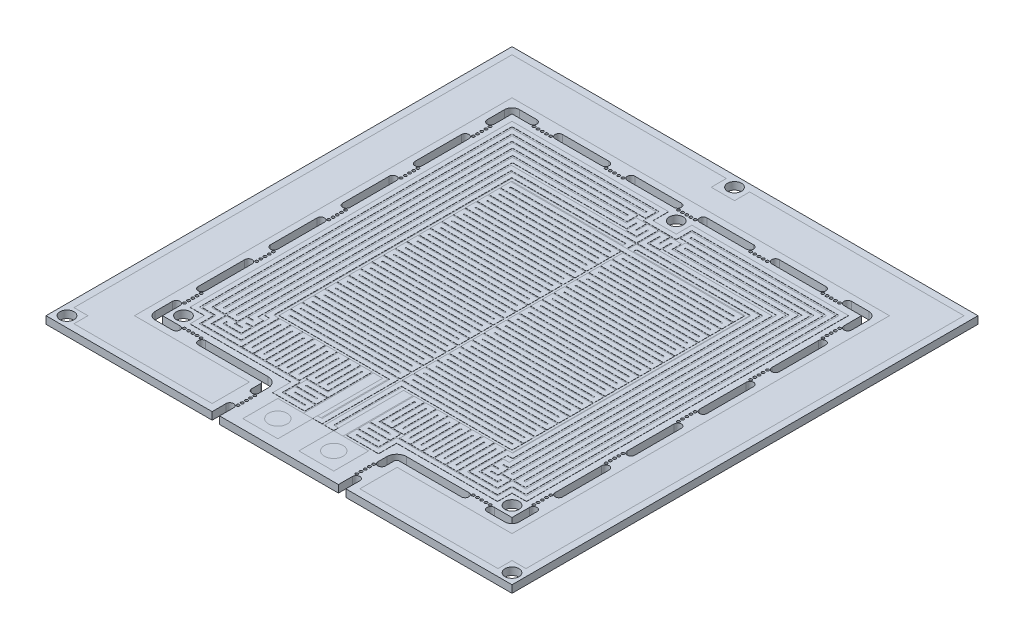
from build123d import *

# Parameters (mm, degrees)
SKETCH1_W           = 100
SKETCH1_H           = 100
BOSS_EXTRUDE1_DEPTH = 1.6
SKETCH2_R           = 1.5
CUT_EXTRUDE1_DEPTH  = 1.6
SKETCH6_R           = 0.3
CUT_EXTRUDE2_DEPTH  = 1.6
SKETCH7_R           = 0.3
CUT_EXTRUDE3_DEPTH  = 1.6
EXTRUDE_THIN1_DEPTH = 0.035
EXTRUDE_THIN2_DEPTH = 0.035


with BuildPart() as part:
    # Sketch1 → Boss-Extrude1 (new body)
    with BuildSketch(Plane(origin=(0, 0, 0), x_dir=(1, 0, 0), z_dir=(0, 1, 0))):
        Rectangle(SKETCH1_W, SKETCH1_H)
    extrude(amount=-BOSS_EXTRUDE1_DEPTH)

    # Sketch2 → Cut-Extrude1 (cut)
    with BuildSketch(Plane(origin=(0, 0, 0), x_dir=(1, 0, 0), z_dir=(0, 1, 0))):
        with Locations((-35.25, -35.25)):
            Circle(SKETCH2_R)
        with Locations((35.25, -35.25)):
            Circle(SKETCH2_R)
        with Locations((0, 35.25)):
            Circle(SKETCH2_R)
        with Locations((-47.75, -47.75)):
            Circle(SKETCH2_R)
        with Locations((47.75, -47.75)):
            Circle(SKETCH2_R)
        with Locations((0, 47.75)):
            Circle(SKETCH2_R)
    extrude(amount=-CUT_EXTRUDE1_DEPTH, mode=Mode.SUBTRACT)

    # Sketch6 → Cut-Extrude2 (cut)
    with BuildSketch(Plane(origin=(0, 0, 0), x_dir=(1, 0, 0), z_dir=(0, 1, 0))):
        with BuildLine():
            Line((12.75, -47), (12.75, -50))
            ThreePointArc((12.75, -50), (13.55, -50.8), (14.35, -50))
            Line((14.35, -50), (14.35, -47))
            ThreePointArc((14.35, -47), (13.55, -46.2), (12.75, -47))
        make_face()
        with Locations((12.75, -46.05)):
            Circle(SKETCH6_R)
        with Locations((12.75, -45.15)):
            Circle(SKETCH6_R)
        with Locations((12.75, -44.25)):
            Circle(SKETCH6_R)
        with Locations((12.75, -43.35)):
            Circle(SKETCH6_R)
        with Locations((12.75, -42.45)):
            Circle(SKETCH6_R)
        with BuildLine():
            ThreePointArc((14.35, -41.5), (13.55, -42.3), (12.75, -41.5))
            Line((12.75, -41.5), (12.75, -39.6))
            ThreePointArc((12.75, -39.6), (13.36507576, -38.11507576), (14.85, -37.5))
            Line((14.85, -37.5), (28.25, -37.5))
            ThreePointArc((28.25, -37.5), (29.05, -38.3), (28.25, -39.1))
            Line((28.25, -39.1), (14.85, -39.1))
            ThreePointArc((14.85, -39.1), (14.496446609, -39.246446609), (14.35, -39.6))
            Line((14.35, -39.6), (14.35, -41.5))
        make_face()
        with BuildLine():
            Line((39.1, -37.5), (39.1, -33.75))
            ThreePointArc((39.1, -33.75), (38.3, -32.95), (37.5, -33.75))
            Line((37.5, -33.75), (37.5, -37.5))
            Line((37.5, -37.5), (33.75, -37.5))
            ThreePointArc((33.75, -37.5), (32.95, -38.3), (33.75, -39.1))
            Line((33.75, -39.1), (37.5, -39.1))
            ThreePointArc((37.5, -39.1), (38.63137085, -38.63137085), (39.1, -37.5))
        make_face()
        with Locations((32.8, -37.5)):
            Circle(SKETCH6_R)
        with Locations((31.9, -37.5)):
            Circle(SKETCH6_R)
        with Locations((31, -37.5)):
            Circle(SKETCH6_R)
        with Locations((30.1, -37.5)):
            Circle(SKETCH6_R)
        with Locations((29.2, -37.5)):
            Circle(SKETCH6_R)
        with BuildLine():
            Line((37.5, -18.25), (37.5, -28.25))
            ThreePointArc((37.5, -28.25), (38.3, -29.05), (39.1, -28.25))
            Line((39.1, -28.25), (39.1, -18.25))
            ThreePointArc((39.1, -18.25), (38.3, -17.45), (37.5, -18.25))
        make_face()
        with BuildLine():
            Line((37.5, -2.75), (37.5, -12.75))
            ThreePointArc((37.5, -12.75), (38.3, -13.55), (39.1, -12.75))
            Line((39.1, -12.75), (39.1, -2.75))
            ThreePointArc((39.1, -2.75), (38.3, -1.95), (37.5, -2.75))
        make_face()
        with Locations((37.5, -32.8)):
            Circle(SKETCH6_R)
        with Locations((37.5, -31.9)):
            Circle(SKETCH6_R)
        with Locations((37.5, -31)):
            Circle(SKETCH6_R)
        with Locations((37.5, -30.1)):
            Circle(SKETCH6_R)
        with Locations((37.5, -29.2)):
            Circle(SKETCH6_R)
        with Locations((37.5, 1.8)):
            Circle(SKETCH6_R)
        with Locations((37.5, 0.9)):
            Circle(SKETCH6_R)
        with Locations((37.5, 0)):
            Circle(SKETCH6_R)
        with Locations((37.5, -0.9)):
            Circle(SKETCH6_R)
        with Locations((37.5, -1.8)):
            Circle(SKETCH6_R)
        with Locations((37.5, -17.3)):
            Circle(SKETCH6_R)
        with Locations((37.5, -16.4)):
            Circle(SKETCH6_R)
        with Locations((37.5, -15.5)):
            Circle(SKETCH6_R)
        with Locations((37.5, -14.6)):
            Circle(SKETCH6_R)
        with Locations((37.5, -13.7)):
            Circle(SKETCH6_R)
        with BuildLine():
            ThreePointArc((37.5, 12.75), (38.3, 13.55), (39.1, 12.75))
            Line((39.1, 12.75), (39.1, 2.75))
            ThreePointArc((39.1, 2.75), (38.3, 1.95), (37.5, 2.75))
            Line((37.5, 2.75), (37.5, 12.75))
        make_face()
        with BuildLine():
            ThreePointArc((37.5, 28.25), (38.3, 29.05), (39.1, 28.25))
            Line((39.1, 28.25), (39.1, 18.25))
            ThreePointArc((39.1, 18.25), (38.3, 17.45), (37.5, 18.25))
            Line((37.5, 18.25), (37.5, 28.25))
        make_face()
        with BuildLine():
            Line((33.75, 39.1), (37.5, 39.1))
            ThreePointArc((37.5, 39.1), (38.63137085, 38.63137085), (39.1, 37.5))
            Line((39.1, 37.5), (39.1, 33.75))
            ThreePointArc((39.1, 33.75), (38.3, 32.95), (37.5, 33.75))
            Line((37.5, 33.75), (37.5, 37.5))
            Line((37.5, 37.5), (33.75, 37.5))
            ThreePointArc((33.75, 37.5), (32.95, 38.3), (33.75, 39.1))
        make_face()
        with Locations((37.5, 13.7)):
            Circle(SKETCH6_R)
        with Locations((37.5, 14.6)):
            Circle(SKETCH6_R)
        with Locations((37.5, 15.5)):
            Circle(SKETCH6_R)
        with Locations((37.5, 16.4)):
            Circle(SKETCH6_R)
        with Locations((37.5, 17.3)):
            Circle(SKETCH6_R)
        with Locations((37.5, 29.2)):
            Circle(SKETCH6_R)
        with Locations((37.5, 30.1)):
            Circle(SKETCH6_R)
        with Locations((37.5, 31)):
            Circle(SKETCH6_R)
        with Locations((37.5, 31.9)):
            Circle(SKETCH6_R)
        with Locations((37.5, 32.8)):
            Circle(SKETCH6_R)
        with BuildLine():
            Line((28.25, 39.1), (18.25, 39.1))
            ThreePointArc((18.25, 39.1), (17.45, 38.3), (18.25, 37.5))
            Line((18.25, 37.5), (28.25, 37.5))
            ThreePointArc((28.25, 37.5), (29.05, 38.3), (28.25, 39.1))
        make_face()
        with Locations((30.1, 37.5)):
            Circle(SKETCH6_R)
        with Locations((31, 37.5)):
            Circle(SKETCH6_R)
        with Locations((31.9, 37.5)):
            Circle(SKETCH6_R)
        with Locations((32.8, 37.5)):
            Circle(SKETCH6_R)
        with Locations((17.3, 37.5)):
            Circle(SKETCH6_R)
        with Locations((16.4, 37.5)):
            Circle(SKETCH6_R)
        with Locations((15.5, 37.5)):
            Circle(SKETCH6_R)
        with Locations((14.6, 37.5)):
            Circle(SKETCH6_R)
        with Locations((13.7, 37.5)):
            Circle(SKETCH6_R)
        with BuildLine():
            Line((12.75, 39.1), (2.75, 39.1))
            ThreePointArc((2.75, 39.1), (1.95, 38.3), (2.75, 37.5))
            Line((2.75, 37.5), (12.75, 37.5))
            ThreePointArc((12.75, 37.5), (13.55, 38.3), (12.75, 39.1))
        make_face()
        with Locations((29.2, 37.5)):
            Circle(SKETCH6_R)
    cut_extrude2 = extrude(amount=-CUT_EXTRUDE2_DEPTH, mode=Mode.SUBTRACT)

    # Mirror1: Cut-Extrude2 across plane
    add(cut_extrude2.mirror(Plane(origin=(0, 0, 0), x_dir=(0, 0, 1), z_dir=(1, 0, 0))), mode=Mode.SUBTRACT)

    # Sketch7 → Cut-Extrude3 (cut)
    with BuildSketch(Plane(origin=(0, 0, 0), x_dir=(1, 0, 0), z_dir=(0, 1, 0))):
        with Locations((1.8, 37.5)):
            Circle(SKETCH7_R)
        with Locations((0.9, 37.5)):
            Circle(SKETCH7_R)
        with Locations((0, 37.5)):
            Circle(SKETCH7_R)
        with Locations((-0.9, 37.5)):
            Circle(SKETCH7_R)
        with Locations((-1.8, 37.5)):
            Circle(SKETCH7_R)
    extrude(amount=-CUT_EXTRUDE3_DEPTH, mode=Mode.SUBTRACT)


with BuildPart() as body_2:
    # Sketch10 → Extrude-Thin1 (new body)
    with BuildSketch(Plane(origin=(0, 0, 0), x_dir=(1, 0, 0), z_dir=(0, 1, 0))):
        Polygon((2.25, -39.5), (1.25, -39.5), (1.25, -25), (25, -25), (25, -22.75), (1.25, -22.75), (1.25, -22.5), (25, -22.5), (25, -20.25), (1.25, -20.25), (1.25, -20), (25, -20), (25, -17.75), (1.25, -17.75), (1.25, -17.5), (25, -17.5), (25, -15.25), (1.25, -15.25), (1.25, -15), (25, -15), (25, -12.75), (1.25, -12.75), (1.25, -12.5), (25, -12.5), (25, -10.25), (1.25, -10.25), (1.25, -10), (25, -10), (25, -7.75), (1.25, -7.75), (1.25, -7.5), (25, -7.5), (25, -5.25), (1.25, -5.25), (1.25, -5), (25, -5), (25, -2.75), (1.25, -2.75), (1.25, -2.5), (25, -2.5), (25, -0.25), (1.25, -0.25), (1.25, 0), (25, 0), (25, 2.25), (1.25, 2.25), (1.25, 2.5), (25, 2.5), (25, 4.75), (1.25, 4.75), (1.25, 5), (25, 5), (25, 7.25), (1.25, 7.25), (1.25, 7.5), (25, 7.5), (25, 9.75), (1.25, 9.75), (1.25, 10), (25, 10), (25, 12.25), (1.25, 12.25), (1.25, 12.5), (25, 12.5), (25, 14.75), (1.25, 14.75), (1.25, 15), (25, 15), (25, 17.25), (1.25, 17.25), (1.25, 17.5), (25, 17.5), (25, 19.75), (1.25, 19.75), (1.25, 20), (25, 20), (25, 22.25), (1.25, 22.25), (1.25, 22.5), (25, 22.5), (25, 24.75), (0, 24.75), (0, 23.75), (24, 23.75), (24, 23.5), (0.25, 23.5), (0.25, 21.25), (24, 21.25), (24, 21), (0.25, 21), (0.25, 18.75), (24, 18.75), (24, 18.5), (0.25, 18.5), (0.25, 16.25), (24, 16.25), (24, 16), (0.25, 16), (0.25, 13.75), (24, 13.75), (24, 13.5), (0.25, 13.5), (0.25, 11.25), (24, 11.25), (24, 11), (0.25, 11), (0.25, 8.75), (24, 8.75), (24, 8.5), (0.25, 8.5), (0.25, 6.25), (24, 6.25), (24, 6), (0.25, 6), (0.25, 3.75), (24, 3.75), (24, 3.5), (0.25, 3.5), (0.25, 1.25), (24, 1.25), (24, 1), (0.25, 1), (0.25, -1.25), (24, -1.25), (24, -1.5), (0.25, -1.5), (0.25, -3.75), (24, -3.75), (24, -4), (0.25, -4), (0.25, -6.25), (24, -6.25), (24, -6.5), (0.25, -6.5), (0.25, -8.75), (24, -8.75), (24, -9), (0.25, -9), (0.25, -11.25), (24, -11.25), (24, -11.5), (0.25, -11.5), (0.25, -13.75), (24, -13.75), (24, -14), (0.25, -14), (0.25, -16.25), (24, -16.25), (24, -16.5), (0.25, -16.5), (0.25, -18.75), (24, -18.75), (24, -19), (0.25, -19), (0.25, -21.25), (24, -21.25), (24, -21.5), (0.25, -21.5), (0.25, -23.75), (24, -23.75), (24, -24), (0.25, -24), (0.25, -40.5), (2.25, -40.5), align=None)
    extrude(amount=EXTRUDE_THIN1_DEPTH)

    # Mirror3: body 2 across plane


with BuildPart() as body_2_1:
    add(body_2.part)
    add(body_2.part.mirror(Plane(origin=(0, 0, 0), x_dir=(0, 0, 1), z_dir=(1, 0, 0))))


with BuildPart() as body_3:
    # Sketch12 → Extrude-Thin2 (new body)
    with BuildSketch(Plane(origin=(0, 0, 0), x_dir=(1, 0, 0), z_dir=(0, 1, 0))):
        Polygon((1.125, 24.75), (1.125, 25.6), (25.65, 25.6), (25.65, -25.5), (24.5, -25.5), (24.5, -33.6), (30.5, -33.6), (30.5, -31.85), (30.5, -30.75), (28.25, -30.75), (28.25, -31.35), (26.75, -31.35), (26.75, -31.1), (28.1, -31.1), (28.1, -28.85), (26.75, -28.85), (26.75, -28.6), (28, -28.6), (28, -26), (28, 27.85), (1.125, 27.85), (1.125, 30.5), (1.375, 30.5), (1.375, 28.1), (3.625, 28.1), (3.625, 30.5), (3.875, 30.5), (3.875, 28.45), (28.35, 28.45), (28.35, -30.5), (30.7, -30.5), (30.7, 30.8), (6.125, 30.8), (6.125, 31.15), (31.05, 31.15), (31.05, -30.5), (33.4, -30.5), (33.4, 33.4), (4.75, 33.4), (4.75, 33.75), (33.75, 33.75), (33.75, -30.75), (30.75, -30.75), (30.75, -33.85), (24.25, -33.85), (24.25, -25.5), (22, -25.5), (22, -33.85), (21.75, -33.85), (21.75, -25.5), (19.5, -25.5), (19.5, -33.85), (19.25, -33.85), (19.25, -25.5), (17, -25.5), (17, -33.85), (16.75, -33.85), (16.75, -25.5), (14.5, -25.5), (14.5, -33.85), (14.25, -33.85), (14.25, -25.5), (12, -25.5), (12, -33.85), (11.75, -33.85), (11.75, -25.5), (9.5, -25.5), (9.5, -32.75), (9.25, -32.75), (9.25, -25.5), (7, -25.5), (7, -32.75), (6.75, -32.75), (6.75, -25.5), (4.5, -25.5), (4.5, -35), (9.1, -35), (9.1, -35.25), (4.5, -35.25), (4.5, -37.5), (9.1, -37.5), (9.1, -37.75), (4.5, -37.75), (4.5, -40), (11.35, -40), (11.35, -36.1), (33, -36.1), (33, -33), (36.1, -33), (36.1, 36.1), (2.5, 36.1), (2.5, 32.75), (0, 32.75), (0, 31.75), (3.5, 31.75), (3.5, 35.1), (35.1, 35.1), (35.1, -32), (32, -32), (32, -35.1), (10.35, -35.1), (10.35, -39), (5.5, -39), (5.5, -38.75), (10.1, -38.75), (10.1, -36.5), (5.5, -36.5), (5.5, -36.25), (10.1, -36.25), (10.1, -34), (5.5, -34), (5.5, -26.5), (5.75, -26.5), (5.75, -33.75), (8, -33.75), (8, -26.5), (8.25, -26.5), (8.25, -33.75), (10.5, -33.75), (10.5, -26.5), (10.75, -26.5), (10.75, -34.85), (13, -34.85), (13, -26.5), (13.25, -26.5), (13.25, -34.85), (15.5, -34.85), (15.5, -26.5), (15.75, -26.5), (15.75, -34.85), (18, -34.85), (18, -26.5), (18.25, -26.5), (18.25, -34.85), (20.5, -34.85), (20.5, -26.5), (20.75, -26.5), (20.75, -34.85), (23, -34.85), (23, -26.5), (23.25, -26.5), (23.25, -34.85), (31.75, -34.85), (31.75, -31.75), (34.75, -31.75), (34.75, 34.75), (3.75, 34.75), (3.75, 32.4), (32.4, 32.4), (32.4, -29.5), (32.05, -29.5), (32.05, 32.15), (5.125, 32.15), (5.125, 29.8), (29.7, 29.8), (29.7, -29.5), (29.35, -29.5), (29.35, 29.45), (4.875, 29.45), (4.875, 31.5), (2.625, 31.5), (2.625, 29.1), (2.375, 29.1), (2.375, 31.5), (0.125, 31.5), (0.125, 26.85), (27, 26.85), (27, -26), (27, -27.6), (25.75, -27.6), (25.75, -29.85), (27.1, -29.85), (27.1, -30.1), (25.75, -30.1), (25.75, -32.35), (29.25, -32.35), (29.25, -31.75), (29.5, -31.75), (29.5, -31.85), (29.5, -32.6), (25.5, -32.6), (25.5, -26.5), (26.65, -26.5), (26.65, 26.6), (0.125, 26.6), (0.125, 24.75), align=None)
    extrude(amount=EXTRUDE_THIN2_DEPTH)

    # Mirror4: body 3 across plane


with BuildPart() as body_3_1:
    add(body_3.part)
    add(body_3.part.mirror(Plane(origin=(0, 0, 0), x_dir=(0, 0, 1), z_dir=(1, 0, 0))))


solid = Compound([part.part, body_2_1.part, body_3_1.part])
